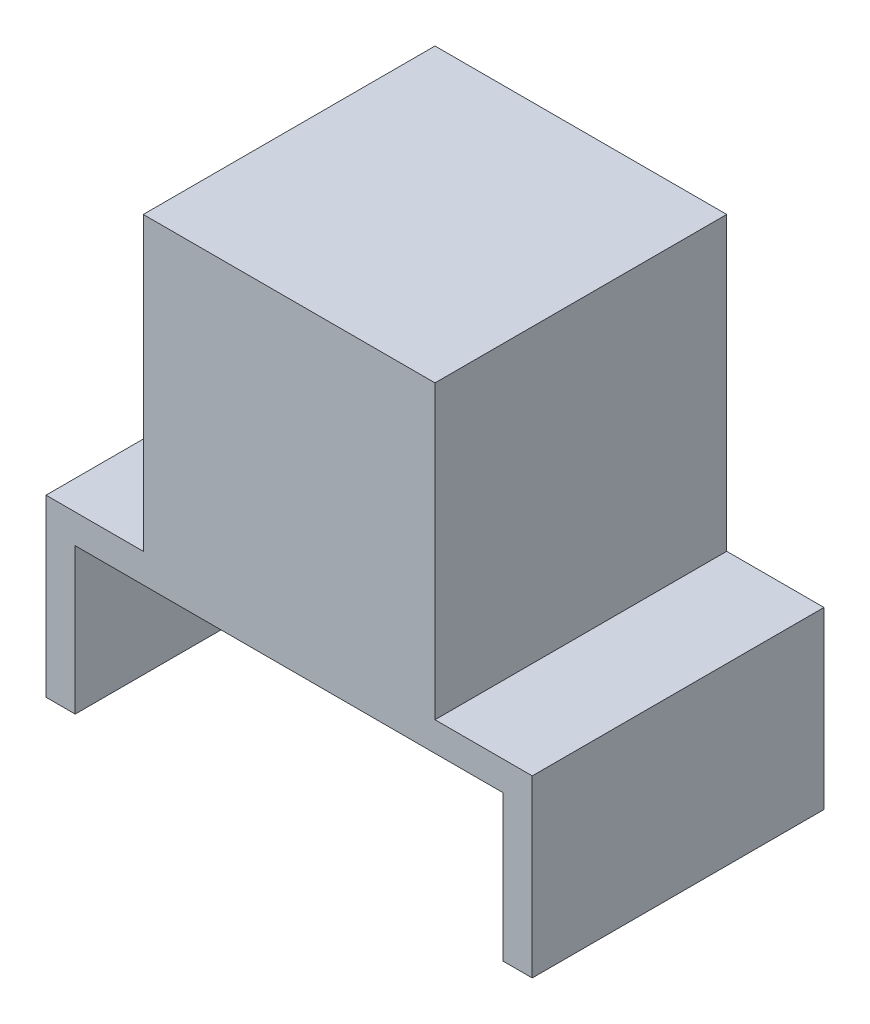
from build123d import *

# Parameters (mm, degrees)
SKETCH_1_W          = 30
SKETCH_1_H          = 30
EXTRUDE_1_DEPTH     = 30
SKETCH_2_W          = 50
SKETCH_2_H          = 40
EXTRUDE_2_DEPTH     = 3
SKETCH_3_W          = 3
SKETCH_3_H          = 40
EXTRUDE_3_DEPTH     = 15
SKETCH_4_W          = 50.744831967
SKETCH_4_H          = 10
CUT_EXTRUDE_1_DEPTH = 19


with BuildPart() as part:
    # 草图1 → 凸台-拉伸1 (new body)
    with BuildSketch(Plane.XY):
        with Locations((6.958041958, 0.594405594)):
            Rectangle(SKETCH_1_W, SKETCH_1_H)
    extrude(amount=EXTRUDE_1_DEPTH)

    # 草图2 → 凸台-拉伸2 (add)
    with BuildSketch(Plane.XZ.offset(14.405594406)):
        with Locations((6.958041958, 20)):
            Rectangle(SKETCH_2_W, SKETCH_2_H)
    extrude(amount=EXTRUDE_2_DEPTH)

    # 草图3 → 凸台-拉伸3 (add)
    with BuildSketch(Plane.XZ.offset(17.405594406)):
        with Locations((-16.541958042, 20)):
            Rectangle(SKETCH_3_W, SKETCH_3_H)
        with Locations((30.458041958, 20)):
            Rectangle(SKETCH_3_W, SKETCH_3_H)
    extrude(amount=EXTRUDE_3_DEPTH)

    # 草图4 → 切除-拉伸1 (cut, through all)
    with BuildSketch(Plane(origin=(0, -14.405594406, 0), x_dir=(1, 0, 0), z_dir=(0, 1, 0))):
        with Locations((6.585625975, -35)):
            Rectangle(SKETCH_4_W, SKETCH_4_H)
    extrude(amount=-CUT_EXTRUDE_1_DEPTH, mode=Mode.SUBTRACT)


solid = part.part
